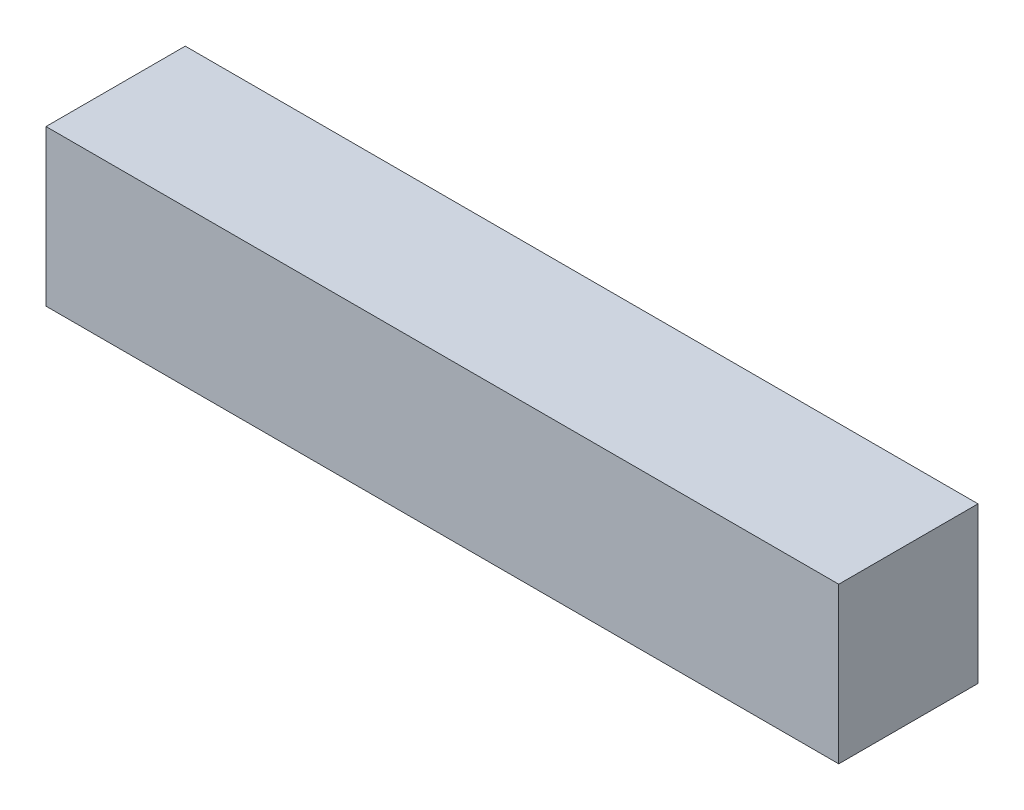
from build123d import *

# Parameters (mm, degrees)
SKETCH2_W           = 101.9
SKETCH2_H           = 17.9
BOSS_EXTRUDE1_DEPTH = 20


with BuildPart() as part:
    # Sketch2 → Boss-Extrude1 (new body)
    with BuildSketch(Plane(origin=(0, 0, 0), x_dir=(1, 0, 0), z_dir=(0, 1, 0))):
        with Locations((0.687412154, -6.236940534)):
            Rectangle(SKETCH2_W, SKETCH2_H)
    extrude(amount=BOSS_EXTRUDE1_DEPTH)


solid = part.part
